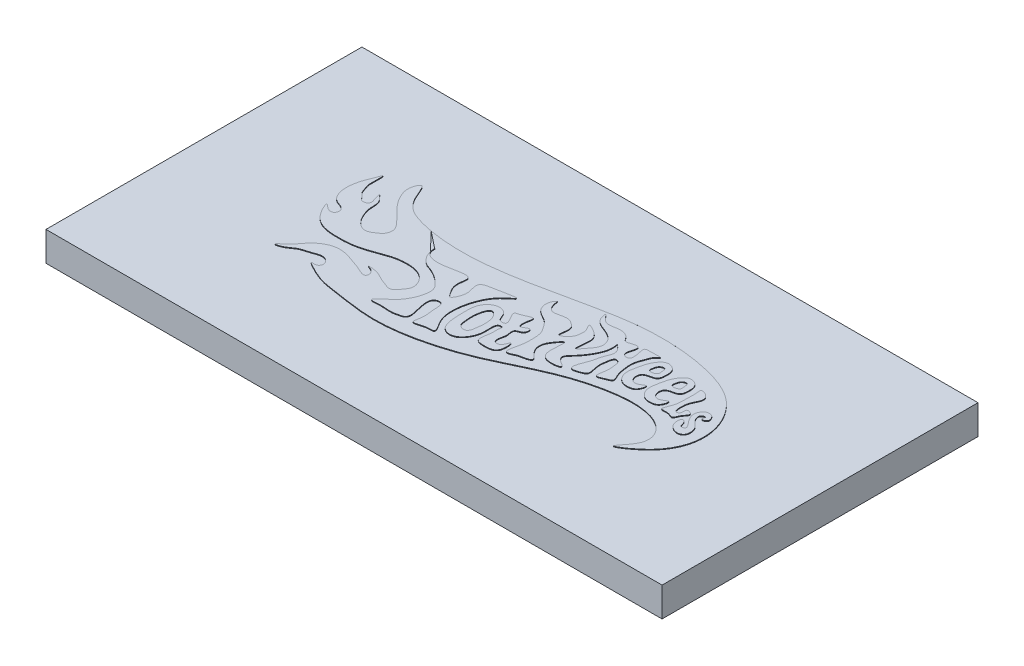
from build123d import *

# Parameters (mm, degrees)
SKETCH1_W           = 86
SKETCH1_H           = 44.1
BOSS_EXTRUDE1_DEPTH = 4.1
BOSS_EXTRUDE3_DEPTH = 0.2
BOSS_EXTRUDE4_DEPTH = 0.1


with BuildPart() as part:
    # Sketch1 → Boss-Extrude1 (new body)
    with BuildSketch(Plane(origin=(0, 0, 0), x_dir=(1, 0, 0), z_dir=(0, 1, 0))):
        Rectangle(SKETCH1_W, SKETCH1_H)
    extrude(amount=-BOSS_EXTRUDE1_DEPTH)

    # Sketch3 → Boss-Extrude3 (add)
    with BuildSketch(Plane(origin=(0, 0, 0), x_dir=(1, 0, 0), z_dir=(0, 1, 0))):
        with BuildLine():
            ThreePointArc((-13.346262233, 2.575413615), (-12.958185311, 1.071468769), (-11.833726119, 0))
            add(Edge.make_bspline(
                [(-13.346262233, 2.575413615), (-13.386916902, 1.010098464), (-10.558808333, 0.862707369), (-7.049789655, 2.070919162), (-7.600187356, 0.033133783), (-7.3753623, -1.070657775), (-6.876226338, -1.709013612), (-6.358746835, -2.53612451), (-5.608363485, -0.996098179), (-5.752434167, -0.042702124), (-6.213385255, 1.487736528), (-4.432886598, 1.88091162), (-3.525362865, 1.989697991), (-1.178763634, 2.526844291), (-2.744139634, 1.331553469), (-3.608047581, 0.349796406), (-4.257207645, -1.340551352), (-4.621407277, -2.819881125), (-4.669267335, -4.529312776), (-4.256582979, -5.896611575), (-2.986827082, -7.612392687), (-4.694936712, -7.352018957), (-6.329502196, -8.285853873), (-5.751069839, -6.348351157), (-6.121190487, -5.29423126), (-5.996706731, -3.38214926), (-7.538759158, -3.605211725), (-7.442336502, -5.587596831), (-6.572113292, -7.67163885), (-7.85261426, -7.944011185), (-8.679223317, -8.162655221), (-9.693788421, -8.059489749), (-10.652534293, -8.023021028), (-12.139970093, -8.256158109), (-10.673023211, -6.949722741), (-9.792028462, -6.305947812), (-8.945560218, -5.027132983), (-8.46194607, -3.685824514), (-8.422903646, -2.41942316), (-9.537323196, -1.023682895), (-10.697255842, -0.357526757), (-11.833726119, 0)],
                knots=[0, 0, 0, 0, 0.059839197, 0.112117778, 0.131457709, 0.153382473, 0.171806344, 0.177534947, 0.19876078, 0.223412698, 0.244570498, 0.266220748, 0.298710328, 0.323693477, 0.334403607, 0.378248818, 0.406589676, 0.427880412, 0.461605135, 0.493408842, 0.517476444, 0.535523462, 0.564297598, 0.581816444, 0.613981389, 0.641561238, 0.65138511, 0.682820934, 0.727371297, 0.738248887, 0.746447999, 0.774523342, 0.789167709, 0.804858102, 0.82936728, 0.84865505, 0.875345261, 0.906270479, 0.927245159, 0.938735001, 1, 1, 1, 1], degree=3))
        make_face()
        with BuildLine():
            add(Edge.make_bspline(
                [(0.279034417, 0.444502331), (0.925542112, 0.60694143), (2.300672608, 1.545704678), (1.823719631, 0.085630155), (1.845865661, -1.204696976), (2.558394135, -0.642300442), (3.21501538, -0.361379707), (3.18863883, -1.24261016), (2.687714679, -1.542024063), (1.818563446, -1.746784296), (2.253155725, -2.801122245), (1.994795315, -3.592726438), (1.884297052, -4.589831932), (3.064801401, -4.629697021), (3.417839301, -2.641744339), (3.779608001, -5.661613145), (2.109797463, -5.749315654), (0.234899352, -5.688006051), (0.976702229, -3.830753748), (0.75389398, -2.893225), (0.991747322, -2.208719759), (-0.00300829, -2.117233206), (0.294683263, -4.043783913), (-0.050155724, -5.286313919), (-0.826933245, -6.372781251), (-1.802706768, -6.89702775), (-2.985973995, -6.568667797), (-3.497885265, -5.463620062), (-3.606145835, -4.240495295), (-3.670809302, -2.759019457), (-3.575446409, -1.225945798), (-2.607075133, -0.124176148), (-1.397717497, 0.122389509), (-0.437545639, -0.571582027), (-0.353426803, -1.701038816), (1.429651593, -1.593657374), (-0.538024717, 0.287786756), (0.21432175, 0.428242869), (0.279034417, 0.444502331)],
                knots=[0, 0, 0, 0, 0.046957887, 0.069811764, 0.096136223, 0.114773168, 0.123907723, 0.143250491, 0.153223646, 0.171150478, 0.201034539, 0.216268104, 0.242332689, 0.257835005, 0.2882186, 0.328269171, 0.374295231, 0.400111586, 0.453459126, 0.473168705, 0.486613643, 0.494124836, 0.534665393, 0.585369858, 0.609224765, 0.635856895, 0.66797017, 0.69188921, 0.726488585, 0.764187914, 0.809319701, 0.84195, 0.87241114, 0.8965654, 0.927218645, 0.942892715, 0.995299715, 1, 1, 1, 1], degree=3))
        make_face()
        with BuildLine():
            add(Edge.make_bspline(
                [(-1.749169159, -0.978732506), (-2.160516395, -0.919810604), (-2.671986222, -2.609408095), (-2.505153028, -3.698669366), (-2.425622701, -5.029590268), (-1.045858899, -5.41665239), (-0.796087282, -3.691278581), (-0.696771684, -2.426808491), (-1.119945861, -1.334965925), (-1.614731514, -0.997989526), (-1.749169159, -0.978732506)],
                knots=[0, 0, 0, 0, 0.151393937, 0.343524612, 0.424303421, 0.52499525, 0.651795589, 0.841336624, 0.950521013, 1, 1, 1, 1], degree=3))
        make_face(mode=Mode.SUBTRACT)
        with BuildLine():
            add(Edge.make_bspline(
                [(1.613015994, 4.742257842), (1.948080942, 1.988201445), (3.793905644, 3.961815142), (5.261327753, 3.014526789), (6.114358568, 2.363862831), (5.169057478, 0.046083737), (7.098377579, 1.525188618), (7.127251287, 2.518189087), (7.199178124, 3.298717108), (6.141859376, 4.552056651), (8.458849536, 3.372876875), (8.758093004, 2.153865387), (8.207056547, -0.440601908), (9.380755156, 1.217910167), (9.956148545, 1.906850072), (10.191851987, 2.924694776), (9.647788547, 3.875423694), (8.718291103, 4.456171624), (7.549416826, 4.840536002), (6.67322719, 5.386393367), (6.38338067, 6.969422381), (7.3985642, 5.28680261), (8.601925499, 5.613113365), (9.713968269, 5.744529131), (10.530178561, 5.4469504), (10.856688229, 5.019875037), (11.255382451, 4.406959831), (11.987397425, 4.973654987), (13.343546877, 4.860460873), (11.927772344, 2.963053828), (13.674108441, 2.664824053), (13.629376656, 3.632535772), (13.543008014, 4.246131246), (13.217060039, 5.194962506), (14.127837833, 5.147370286), (14.679986676, 5.156664284), (15.895837054, 5.287158542), (15.051683894, 4.715907679), (14.772864669, 3.916833119), (14.216773415, 2.662690353), (14.40314759, 1.192873867), (14.611341905, 0.09898772), (15.26735595, -0.939087856), (14.24056968, -1.238847549), (12.993692037, -1.928469018), (13.507536741, -0.110391364), (13.334351098, 0.758971806), (13.286042826, 1.657625939), (12.406087639, 2.017138402), (12.320495493, 0.935576642), (12.172485324, 0.128303239), (12.256144913, -0.715804767), (12.615803063, -1.798114665), (11.700034266, -2.242574345), (10.098431831, -2.81405155), (10.814077985, -0.890694877), (11.243901084, 0.116117949), (11.395510031, 1.694368434), (12.407410955, 2.717524189), (10.97277172, 3.708479176)],
                knots=[0, 0, 0, 0, 0.060321315, 0.069200984, 0.083477112, 0.110036045, 0.135282551, 0.148903644, 0.160609983, 0.174607724, 0.202037838, 0.222571117, 0.251779093, 0.271812447, 0.285660255, 0.301278405, 0.318010866, 0.335594669, 0.354048774, 0.37721853, 0.388764246, 0.404752755, 0.430919099, 0.446873304, 0.459249566, 0.471089737, 0.472785746, 0.494018031, 0.500536672, 0.531239803, 0.543623034, 0.556290147, 0.566407783, 0.579428268, 0.590761482, 0.598306082, 0.613641812, 0.62095047, 0.633763604, 0.658310454, 0.685182441, 0.702767997, 0.717367812, 0.730181354, 0.746860713, 0.767220846, 0.788852143, 0.799402092, 0.806564328, 0.825590469, 0.833014513, 0.849186709, 0.868492003, 0.87559469, 0.897096305, 0.925736795, 0.936584988, 0.955006175, 1, 1, 1, 1], degree=3))
            add(Edge.make_bspline(
                [(10.97277172, 3.708479176), (11.244069198, 2.660925959), (10.554062002, 0.993456491), (9.462142687, -0.488417404), (8.346923422, -1.585569096), (9.061066247, -2.337898584), (10.387428066, -2.984726913), (7.601785693, -3.39458142), (6.757447826, -1.837928989), (7.438837593, 1.075461471), (6.110398795, -0.588008722), (5.587441026, -1.616863379), (5.803092686, -2.982387396), (7.512001756, -4.135671057), (5.878784148, -4.419270345), (5.232188606, -4.579796957), (4.789817939, -4.811911317), (3.712360481, -5.234549379), (4.38691175, -3.064597682), (4.412312829, -1.684787415), (4.382235796, -0.287481625), (3.721625474, 0.65426636), (3.090532819, 1.716074951), (1.013695852, 2.268848074), (0.953255896, 4.245114176), (1.613015994, 4.742257842)],
                knots=[0, 0, 0, 0, 0.09682369, 0.154269235, 0.18712018, 0.21634845, 0.237407293, 0.294977142, 0.342643308, 0.40856045, 0.443323884, 0.480219026, 0.525363228, 0.566169121, 0.606783623, 0.623600692, 0.632962653, 0.65478217, 0.706368102, 0.757431757, 0.814726255, 0.821594798, 0.865099277, 0.926689155, 1, 1, 1, 1], degree=3))
        make_face()
        with BuildLine():
            add(Edge.make_bspline(
                [(18.012952955, 0.729860988), (18.141151348, 0.639969874), (17.854842841, -0.440557189), (16.955238167, -0.668612034), (15.876432631, -0.653542953), (14.807858782, 0.475366694), (15.118858562, 2.306558266), (15.482706119, 3.913352632), (16.536267675, 5.101715984), (17.474501546, 4.89606399), (18.108998941, 4.340192141), (18.128434729, 3.420502658), (18.054969225, 2.46681644), (17.328617181, 2.173232731), (16.796685347, 2.111962489), (16.011213213, 1.715816004), (16.100039487, 0.477910135), (17.160365701, 0.110823069), (17.879178013, 0.823662308), (18.012952955, 0.729860988)],
                knots=[0, 0, 0, 0, 0.058617221, 0.109868635, 0.159717105, 0.238302361, 0.340664773, 0.45871918, 0.534624742, 0.574947215, 0.611656686, 0.671743631, 0.728229756, 0.755585897, 0.797620319, 0.823081265, 0.900005156, 0.938832967, 1, 1, 1, 1], degree=3))
        make_face()
        with BuildLine():
            add(Edge.make_bspline(
                [(16.329530781, 2.876456338), (16.472370109, 2.627258414), (17.553850543, 2.799347563), (17.35801432, 3.571530838), (17.319426347, 4.187116122), (16.783657752, 4.149184463), (16.428963551, 3.81756734), (16.339065899, 3.355215344), (16.269463623, 2.981249685), (16.329530781, 2.876456338)],
                knots=[0, 0, 0, 0, 0.255352898, 0.419254199, 0.550807183, 0.630732832, 0.76010809, 0.892618348, 1, 1, 1, 1], degree=3))
        make_face(mode=Mode.SUBTRACT)
        with BuildLine():
            add(Edge.make_bspline(
                [(26.46793944, 0.751718698), (26.310821901, 0.579721327), (25.658470822, 0.382887736), (26.096251149, 1.224418923), (25.104090474, 0.887889284), (25.64687071, -0.318192111), (26.716702783, -0.847243666), (26.868422066, -2.575451644), (25.513855856, -2.921504778), (24.743883985, -2.371972535), (24.371409862, -1.647174316), (24.379112304, -0.581741083), (25.231506171, -1.048320916), (25.144325269, -1.905796624), (26.17747787, -1.601728423), (24.884132382, -0.370488384), (24.5566732, 0.804913462), (25.249440318, 1.794529016), (26.048065146, 1.880211213), (26.516672997, 1.391886076), (26.627631536, 0.92653445), (26.46793944, 0.751718698)],
                knots=[0, 0, 0, 0, 0.037321151, 0.066396701, 0.090042746, 0.160448429, 0.232248066, 0.331250289, 0.381571745, 0.459124011, 0.482320231, 0.545390293, 0.570086438, 0.626119895, 0.648504735, 0.718363636, 0.83475127, 0.878958339, 0.925894513, 0.962067298, 1, 1, 1, 1], degree=3))
        make_face()
        with BuildLine():
            add(Edge.make_bspline(
                [(21.478629048, 0.41568997), (21.606827441, 0.325798856), (21.320518934, -0.754728207), (20.42091426, -0.982783052), (19.342108724, -0.967713971), (18.273534874, 0.161195676), (18.584534655, 1.992387248), (18.948382212, 3.599181614), (20.001943768, 4.787544966), (20.940177639, 4.581892972), (21.574675034, 4.026021123), (21.594110822, 3.10633164), (21.520645318, 2.152645422), (20.794293273, 1.859061713), (20.26236144, 1.797791471), (19.476889306, 1.401644986), (19.56571558, 0.163739117), (20.626041794, -0.203347949), (21.344854106, 0.50949129), (21.478629048, 0.41568997)],
                knots=[0, 0, 0, 0, 0.058617221, 0.109868635, 0.159717105, 0.238302361, 0.340664773, 0.45871918, 0.534624742, 0.574947215, 0.611656686, 0.671743631, 0.728229756, 0.755585897, 0.797620319, 0.823081265, 0.900005156, 0.938832967, 1, 1, 1, 1], degree=3))
        make_face()
        with BuildLine():
            add(Edge.make_bspline(
                [(19.725622139, 2.611687731), (19.868461466, 2.362489806), (20.949941901, 2.534578955), (20.754105677, 3.30676223), (20.715517705, 3.922347514), (20.179749109, 3.884415856), (19.825054908, 3.552798732), (19.735157257, 3.090446736), (19.66555498, 2.716481078), (19.725622139, 2.611687731)],
                knots=[0, 0, 0, 0, 0.255352898, 0.419254199, 0.550807183, 0.630732832, 0.76010809, 0.892618348, 1, 1, 1, 1], degree=3))
        make_face(mode=Mode.SUBTRACT)
        with BuildLine():
            add(Edge.make_bspline(
                [(22.395924717, 3.964146807), (22.568689374, 4.211486567), (24.072444249, 3.491380309), (23.197227519, 1.991587032), (22.911781657, 1.031198443), (23.044633442, -0.588320659), (23.872008437, -0.095644708), (23.501435205, 0.87432531), (24.883191791, 0.400639871), (23.901877328, -0.360944074), (23.729072326, -1.526492604), (22.813275123, -0.856806753), (21.573304318, -1.236573427), (22.296563507, 0.295934173), (22.411487498, 1.304938121), (22.378382062, 2.543941734), (22.43889375, 3.251284004), (22.307751805, 3.837913427), (22.395924717, 3.964146807)],
                knots=[0, 0, 0, 0, 0.081733134, 0.162612751, 0.267608388, 0.331329602, 0.358115367, 0.407066741, 0.451608689, 0.510127419, 0.572746225, 0.618594364, 0.683676624, 0.732948124, 0.851989086, 0.914118909, 0.958286327, 1, 1, 1, 1], degree=3))
        make_face()
    extrude(amount=BOSS_EXTRUDE3_DEPTH)

    # Sketch3_5 → Boss-Extrude4 (add)
    with BuildSketch(Plane(origin=(0, 0, 0), x_dir=(1, 0, 0), z_dir=(0, 1, 0))):
        with BuildLine():
            add(Edge.make_bspline(
                [(22.868095701, -8.659983195), (22.853369052, -8.92245337), (29.981816264, -4.462245521), (27.654180563, 4.33480809), (20.878736025, 6.928903291), (15.55245501, 7.794614627), (10.156991481, 7.727810484), (4.992783318, 6.737707377), (0.158076145, 5.695134645), (-5.971099811, 4.405969666), (-12.211969754, 3.864672556), (-18.065794281, 4.885489561), (-20.786171754, 6.271629858), (-21.865832287, 10.107486919), (-22.669493029, 8.188159378), (-22.352687727, 6.813606294), (-21.369620817, 5.249589503), (-20.134872412, 4.107387403), (-19.186193453, 3.090079121), (-18.428356874, 2.192667186), (-18.621495888, 1.038791556), (-19.477979094, 0.424435803), (-20.536418787, -0.262076511), (-21.846190366, 0.558320667), (-22.474184446, 1.677633763), (-22.896093362, 2.818087196), (-22.83783068, 3.740012971), (-22.998526768, 4.522014084), (-23.388083391, 4.852242936), (-23.966963514, 5.610912612), (-23.711645596, 4.755073731), (-23.553274156, 4.303370804), (-23.361912996, 3.688907381), (-23.864329749, 3.327948127), (-24.452438984, 3.293147945), (-24.750125654, 3.908034648), (-25.355706193, 4.273931767), (-25.544004626, 5.054255297), (-25.844694693, 5.698989556), (-25.783443578, 6.385273222), (-25.804743922, 6.967120682), (-25.766673644, 8.328370369), (-26.340132454, 6.706572248), (-26.872725838, 5.412275023), (-27.277953205, 3.262267912), (-26.249392166, 1.548435131), (-25.212348725, 1.328326426), (-24.472469746, 0.733298068), (-24.811421971, -0.165967016), (-25.700215454, -0.127585885), (-26.691895138, 1.026081978), (-25.281024382, -2.412195217), (-22.725649609, -2.766774097), (-19.517794437, -2.694164609), (-17.298192351, -1.987765708), (-15.281318713, -1.17294477), (-13.46027236, -1.012736531), (-11.760636478, -1.242282681), (-10.575515792, -2.202419189), (-10.136585527, -3.60319017), (-10.832060687, -4.560980253), (-11.566164325, -5.527604605), (-12.585976185, -5.12556004), (-13.448135322, -4.82494147), (-14.268092473, -4.299101514), (-15.124965167, -4.10652395), (-15.61939007, -4.048467036), (-16.274242499, -4.038250762), (-14.848449021, -4.325665816), (-14.862811522, -5.857381639), (-16.289282016, -5.055174919), (-17.188337645, -4.772211291), (-18.335583548, -4.346366119), (-19.704176368, -3.912335531), (-21.515178469, -4.227094587), (-23.097203016, -5.484566395), (-23.715351812, -6.705857902), (-25.751215075, -8.22078381), (-23.904035948, -7.608972181), (-23.14791385, -6.773629159), (-21.681746509, -6.518418752), (-20.554519539, -5.925444958), (-19.524975327, -6.298347652), (-19.192360311, -7.127637218), (-19.703767407, -7.71596818), (-20.820752648, -7.460384328), (-17.89776098, -9.111422762), (-15.522681196, -9.359126251), (-9.928422785, -10.384794323), (-3.909229593, -9.727529501), (1.822353215, -7.985021167), (7.062329772, -5.381851823), (11.565186125, -3.389934173), (16.217433599, -2.233960762), (20.152991008, -1.925212844), (22.938211208, -2.809731965), (24.42240102, -4.288590893), (24.986685464, -6.428661915), (22.880285569, -8.44272557), (22.868095701, -8.659983195)],
                knots=[0, 0, 0, 0, 0.01701836, 0.073096355, 0.099671074, 0.122109631, 0.153792444, 0.179539325, 0.200561429, 0.227718364, 0.272969621, 0.294218052, 0.313134707, 0.323667692, 0.328462939, 0.336044891, 0.345534222, 0.355164013, 0.361107985, 0.366573873, 0.371860247, 0.376166821, 0.382188725, 0.388981624, 0.395891844, 0.401663906, 0.406597174, 0.409900165, 0.412570989, 0.415438788, 0.418393073, 0.420225243, 0.424002358, 0.425857289, 0.428754204, 0.431425027, 0.435112198, 0.438878187, 0.442818417, 0.445715332, 0.448612247, 0.452967265, 0.457762513, 0.463628318, 0.479006544, 0.486078814, 0.490491264, 0.494797837, 0.498034654, 0.501800643, 0.506453575, 0.51231938, 0.535000577, 0.546602713, 0.559535418, 0.569612352, 0.578923128, 0.586593117, 0.594605588, 0.600577731, 0.606150058, 0.61190027, 0.616048021, 0.62072813, 0.625970498, 0.630411339, 0.633322702, 0.634191777, 0.63846902, 0.643184856, 0.649720594, 0.654670844, 0.658977418, 0.667619746, 0.675859419, 0.685593225, 0.695051553, 0.702016208, 0.706872323, 0.713782542, 0.721111222, 0.727717204, 0.732129653, 0.735793993, 0.739071478, 0.741968393, 0.747190881, 0.767531267, 0.795558076, 0.823464856, 0.859481093, 0.883720153, 0.910995802, 0.932776673, 0.95509044, 0.969400144, 0.974407095, 0.985913186, 1, 1, 1, 1], degree=3))
        make_face()
        with BuildLine():
            add(Edge.make_bspline(
                [(-13.346262233, 2.575413615), (-13.386916902, 1.010098464), (-10.558808333, 0.862707369), (-7.049789655, 2.070919162), (-7.600187356, 0.033133783), (-7.3753623, -1.070657775), (-6.876226338, -1.709013612), (-6.358746835, -2.53612451), (-5.608363485, -0.996098179), (-5.752434167, -0.042702124), (-6.213385255, 1.487736528), (-4.432886598, 1.88091162), (-3.525362865, 1.989697991), (-1.178763634, 2.526844291), (-2.744139634, 1.331553469), (-3.608047581, 0.349796406), (-4.257207645, -1.340551352), (-4.621407277, -2.819881125), (-4.669267335, -4.529312776), (-4.256582979, -5.896611575), (-2.986827082, -7.612392687), (-4.694936712, -7.352018957), (-6.329502196, -8.285853873), (-5.751069839, -6.348351157), (-6.121190487, -5.29423126), (-5.996706731, -3.38214926), (-7.538759158, -3.605211725), (-7.442336502, -5.587596831), (-6.572113292, -7.67163885), (-7.85261426, -7.944011185), (-8.679223317, -8.162655221), (-9.693788421, -8.059489749), (-10.652534293, -8.023021028), (-12.139970093, -8.256158109), (-10.673023211, -6.949722741), (-9.792028462, -6.305947812), (-8.945560218, -5.027132983), (-8.46194607, -3.685824514), (-8.422903646, -2.41942316), (-9.537323196, -1.023682895), (-10.697255842, -0.357526757), (-11.833726119, 0)],
                knots=[0, 0, 0, 0, 0.059839197, 0.112117778, 0.131457709, 0.153382473, 0.171806344, 0.177534947, 0.19876078, 0.223412698, 0.244570498, 0.266220748, 0.298710328, 0.323693477, 0.334403607, 0.378248818, 0.406589676, 0.427880412, 0.461605135, 0.493408842, 0.517476444, 0.535523462, 0.564297598, 0.581816444, 0.613981389, 0.641561238, 0.65138511, 0.682820934, 0.727371297, 0.738248887, 0.746447999, 0.774523342, 0.789167709, 0.804858102, 0.82936728, 0.84865505, 0.875345261, 0.906270479, 0.927245159, 0.938735001, 1, 1, 1, 1], degree=3))
            ThreePointArc((-11.833726119, 0), (-12.958185311, 1.071468769), (-13.346262233, 2.575413615))
        make_face(mode=Mode.SUBTRACT)
        with BuildLine():
            add(Edge.make_bspline(
                [(0.279034417, 0.444502331), (0.925542112, 0.60694143), (2.300672608, 1.545704678), (1.823719631, 0.085630155), (1.845865661, -1.204696976), (2.558394135, -0.642300442), (3.21501538, -0.361379707), (3.18863883, -1.24261016), (2.687714679, -1.542024063), (1.818563446, -1.746784296), (2.253155725, -2.801122245), (1.994795315, -3.592726438), (1.884297052, -4.589831932), (3.064801401, -4.629697021), (3.417839301, -2.641744339), (3.779608001, -5.661613145), (2.109797463, -5.749315654), (0.234899352, -5.688006051), (0.976702229, -3.830753748), (0.75389398, -2.893225), (0.991747322, -2.208719759), (-0.00300829, -2.117233206), (0.294683263, -4.043783913), (-0.050155724, -5.286313919), (-0.826933245, -6.372781251), (-1.802706768, -6.89702775), (-2.985973995, -6.568667797), (-3.497885265, -5.463620062), (-3.606145835, -4.240495295), (-3.670809302, -2.759019457), (-3.575446409, -1.225945798), (-2.607075133, -0.124176148), (-1.397717497, 0.122389509), (-0.437545639, -0.571582027), (-0.353426803, -1.701038816), (1.429651593, -1.593657374), (-0.538024717, 0.287786756), (0.21432175, 0.428242869), (0.279034417, 0.444502331)],
                knots=[0, 0, 0, 0, 0.046957887, 0.069811764, 0.096136223, 0.114773168, 0.123907723, 0.143250491, 0.153223646, 0.171150478, 0.201034539, 0.216268104, 0.242332689, 0.257835005, 0.2882186, 0.328269171, 0.374295231, 0.400111586, 0.453459126, 0.473168705, 0.486613643, 0.494124836, 0.534665393, 0.585369858, 0.609224765, 0.635856895, 0.66797017, 0.69188921, 0.726488585, 0.764187914, 0.809319701, 0.84195, 0.87241114, 0.8965654, 0.927218645, 0.942892715, 0.995299715, 1, 1, 1, 1], degree=3))
        make_face(mode=Mode.SUBTRACT)
        with BuildLine():
            add(Edge.make_bspline(
                [(26.46793944, 0.751718698), (26.310821901, 0.579721327), (25.658470822, 0.382887736), (26.096251149, 1.224418923), (25.104090474, 0.887889284), (25.64687071, -0.318192111), (26.716702783, -0.847243666), (26.868422066, -2.575451644), (25.513855856, -2.921504778), (24.743883985, -2.371972535), (24.371409862, -1.647174316), (24.379112304, -0.581741083), (25.231506171, -1.048320916), (25.144325269, -1.905796624), (26.17747787, -1.601728423), (24.884132382, -0.370488384), (24.5566732, 0.804913462), (25.249440318, 1.794529016), (26.048065146, 1.880211213), (26.516672997, 1.391886076), (26.627631536, 0.92653445), (26.46793944, 0.751718698)],
                knots=[0, 0, 0, 0, 0.037321151, 0.066396701, 0.090042746, 0.160448429, 0.232248066, 0.331250289, 0.381571745, 0.459124011, 0.482320231, 0.545390293, 0.570086438, 0.626119895, 0.648504735, 0.718363636, 0.83475127, 0.878958339, 0.925894513, 0.962067298, 1, 1, 1, 1], degree=3))
        make_face(mode=Mode.SUBTRACT)
        with BuildLine():
            add(Edge.make_bspline(
                [(10.97277172, 3.708479176), (11.244069198, 2.660925959), (10.554062002, 0.993456491), (9.462142687, -0.488417404), (8.346923422, -1.585569096), (9.061066247, -2.337898584), (10.387428066, -2.984726913), (7.601785693, -3.39458142), (6.757447826, -1.837928989), (7.438837593, 1.075461471), (6.110398795, -0.588008722), (5.587441026, -1.616863379), (5.803092686, -2.982387396), (7.512001756, -4.135671057), (5.878784148, -4.419270345), (5.232188606, -4.579796957), (4.789817939, -4.811911317), (3.712360481, -5.234549379), (4.38691175, -3.064597682), (4.412312829, -1.684787415), (4.382235796, -0.287481625), (3.721625474, 0.65426636), (3.090532819, 1.716074951), (1.013695852, 2.268848074), (0.953255896, 4.245114176), (1.613015994, 4.742257842)],
                knots=[0, 0, 0, 0, 0.09682369, 0.154269235, 0.18712018, 0.21634845, 0.237407293, 0.294977142, 0.342643308, 0.40856045, 0.443323884, 0.480219026, 0.525363228, 0.566169121, 0.606783623, 0.623600692, 0.632962653, 0.65478217, 0.706368102, 0.757431757, 0.814726255, 0.821594798, 0.865099277, 0.926689155, 1, 1, 1, 1], degree=3))
            add(Edge.make_bspline(
                [(1.613015994, 4.742257842), (1.948080942, 1.988201445), (3.793905644, 3.961815142), (5.261327753, 3.014526789), (6.114358568, 2.363862831), (5.169057478, 0.046083737), (7.098377579, 1.525188618), (7.127251287, 2.518189087), (7.199178124, 3.298717108), (6.141859376, 4.552056651), (8.458849536, 3.372876875), (8.758093004, 2.153865387), (8.207056547, -0.440601908), (9.380755156, 1.217910167), (9.956148545, 1.906850072), (10.191851987, 2.924694776), (9.647788547, 3.875423694), (8.718291103, 4.456171624), (7.549416826, 4.840536002), (6.67322719, 5.386393367), (6.38338067, 6.969422381), (7.3985642, 5.28680261), (8.601925499, 5.613113365), (9.713968269, 5.744529131), (10.530178561, 5.4469504), (10.856688229, 5.019875037), (11.255382451, 4.406959831), (11.987397425, 4.973654987), (13.343546877, 4.860460873), (11.927772344, 2.963053828), (13.674108441, 2.664824053), (13.629376656, 3.632535772), (13.543008014, 4.246131246), (13.217060039, 5.194962506), (14.127837833, 5.147370286), (14.679986676, 5.156664284), (15.895837054, 5.287158542), (15.051683894, 4.715907679), (14.772864669, 3.916833119), (14.216773415, 2.662690353), (14.40314759, 1.192873867), (14.611341905, 0.09898772), (15.26735595, -0.939087856), (14.24056968, -1.238847549), (12.993692037, -1.928469018), (13.507536741, -0.110391364), (13.334351098, 0.758971806), (13.286042826, 1.657625939), (12.406087639, 2.017138402), (12.320495493, 0.935576642), (12.172485324, 0.128303239), (12.256144913, -0.715804767), (12.615803063, -1.798114665), (11.700034266, -2.242574345), (10.098431831, -2.81405155), (10.814077985, -0.890694877), (11.243901084, 0.116117949), (11.395510031, 1.694368434), (12.407410955, 2.717524189), (10.97277172, 3.708479176)],
                knots=[0, 0, 0, 0, 0.060321315, 0.069200984, 0.083477112, 0.110036045, 0.135282551, 0.148903644, 0.160609983, 0.174607724, 0.202037838, 0.222571117, 0.251779093, 0.271812447, 0.285660255, 0.301278405, 0.318010866, 0.335594669, 0.354048774, 0.37721853, 0.388764246, 0.404752755, 0.430919099, 0.446873304, 0.459249566, 0.471089737, 0.472785746, 0.494018031, 0.500536672, 0.531239803, 0.543623034, 0.556290147, 0.566407783, 0.579428268, 0.590761482, 0.598306082, 0.613641812, 0.62095047, 0.633763604, 0.658310454, 0.685182441, 0.702767997, 0.717367812, 0.730181354, 0.746860713, 0.767220846, 0.788852143, 0.799402092, 0.806564328, 0.825590469, 0.833014513, 0.849186709, 0.868492003, 0.87559469, 0.897096305, 0.925736795, 0.936584988, 0.955006175, 1, 1, 1, 1], degree=3))
        make_face(mode=Mode.SUBTRACT)
        with BuildLine():
            add(Edge.make_bspline(
                [(18.012952955, 0.729860988), (18.141151348, 0.639969874), (17.854842841, -0.440557189), (16.955238167, -0.668612034), (15.876432631, -0.653542953), (14.807858782, 0.475366694), (15.118858562, 2.306558266), (15.482706119, 3.913352632), (16.536267675, 5.101715984), (17.474501546, 4.89606399), (18.108998941, 4.340192141), (18.128434729, 3.420502658), (18.054969225, 2.46681644), (17.328617181, 2.173232731), (16.796685347, 2.111962489), (16.011213213, 1.715816004), (16.100039487, 0.477910135), (17.160365701, 0.110823069), (17.879178013, 0.823662308), (18.012952955, 0.729860988)],
                knots=[0, 0, 0, 0, 0.058617221, 0.109868635, 0.159717105, 0.238302361, 0.340664773, 0.45871918, 0.534624742, 0.574947215, 0.611656686, 0.671743631, 0.728229756, 0.755585897, 0.797620319, 0.823081265, 0.900005156, 0.938832967, 1, 1, 1, 1], degree=3))
        make_face(mode=Mode.SUBTRACT)
        with BuildLine():
            add(Edge.make_bspline(
                [(21.478629048, 0.41568997), (21.606827441, 0.325798856), (21.320518934, -0.754728207), (20.42091426, -0.982783052), (19.342108724, -0.967713971), (18.273534874, 0.161195676), (18.584534655, 1.992387248), (18.948382212, 3.599181614), (20.001943768, 4.787544966), (20.940177639, 4.581892972), (21.574675034, 4.026021123), (21.594110822, 3.10633164), (21.520645318, 2.152645422), (20.794293273, 1.859061713), (20.26236144, 1.797791471), (19.476889306, 1.401644986), (19.56571558, 0.163739117), (20.626041794, -0.203347949), (21.344854106, 0.50949129), (21.478629048, 0.41568997)],
                knots=[0, 0, 0, 0, 0.058617221, 0.109868635, 0.159717105, 0.238302361, 0.340664773, 0.45871918, 0.534624742, 0.574947215, 0.611656686, 0.671743631, 0.728229756, 0.755585897, 0.797620319, 0.823081265, 0.900005156, 0.938832967, 1, 1, 1, 1], degree=3))
        make_face(mode=Mode.SUBTRACT)
        with BuildLine():
            add(Edge.make_bspline(
                [(22.395924717, 3.964146807), (22.568689374, 4.211486567), (24.072444249, 3.491380309), (23.197227519, 1.991587032), (22.911781657, 1.031198443), (23.044633442, -0.588320659), (23.872008437, -0.095644708), (23.501435205, 0.87432531), (24.883191791, 0.400639871), (23.901877328, -0.360944074), (23.729072326, -1.526492604), (22.813275123, -0.856806753), (21.573304318, -1.236573427), (22.296563507, 0.295934173), (22.411487498, 1.304938121), (22.378382062, 2.543941734), (22.43889375, 3.251284004), (22.307751805, 3.837913427), (22.395924717, 3.964146807)],
                knots=[0, 0, 0, 0, 0.081733134, 0.162612751, 0.267608388, 0.331329602, 0.358115367, 0.407066741, 0.451608689, 0.510127419, 0.572746225, 0.618594364, 0.683676624, 0.732948124, 0.851989086, 0.914118909, 0.958286327, 1, 1, 1, 1], degree=3))
        make_face(mode=Mode.SUBTRACT)
        with BuildLine():
            add(Edge.make_bspline(
                [(-1.749169159, -0.978732506), (-2.160516395, -0.919810604), (-2.671986222, -2.609408095), (-2.505153028, -3.698669366), (-2.425622701, -5.029590268), (-1.045858899, -5.41665239), (-0.796087282, -3.691278581), (-0.696771684, -2.426808491), (-1.119945861, -1.334965925), (-1.614731514, -0.997989526), (-1.749169159, -0.978732506)],
                knots=[0, 0, 0, 0, 0.151393937, 0.343524612, 0.424303421, 0.52499525, 0.651795589, 0.841336624, 0.950521013, 1, 1, 1, 1], degree=3))
        make_face()
        with BuildLine():
            add(Edge.make_bspline(
                [(16.329530781, 2.876456338), (16.472370109, 2.627258414), (17.553850543, 2.799347563), (17.35801432, 3.571530838), (17.319426347, 4.187116122), (16.783657752, 4.149184463), (16.428963551, 3.81756734), (16.339065899, 3.355215344), (16.269463623, 2.981249685), (16.329530781, 2.876456338)],
                knots=[0, 0, 0, 0, 0.255352898, 0.419254199, 0.550807183, 0.630732832, 0.76010809, 0.892618348, 1, 1, 1, 1], degree=3))
        make_face()
        with BuildLine():
            add(Edge.make_bspline(
                [(19.725622139, 2.611687731), (19.868461466, 2.362489806), (20.949941901, 2.534578955), (20.754105677, 3.30676223), (20.715517705, 3.922347514), (20.179749109, 3.884415856), (19.825054908, 3.552798732), (19.735157257, 3.090446736), (19.66555498, 2.716481078), (19.725622139, 2.611687731)],
                knots=[0, 0, 0, 0, 0.255352898, 0.419254199, 0.550807183, 0.630732832, 0.76010809, 0.892618348, 1, 1, 1, 1], degree=3))
        make_face()
    extrude(amount=BOSS_EXTRUDE4_DEPTH)


solid = part.part
